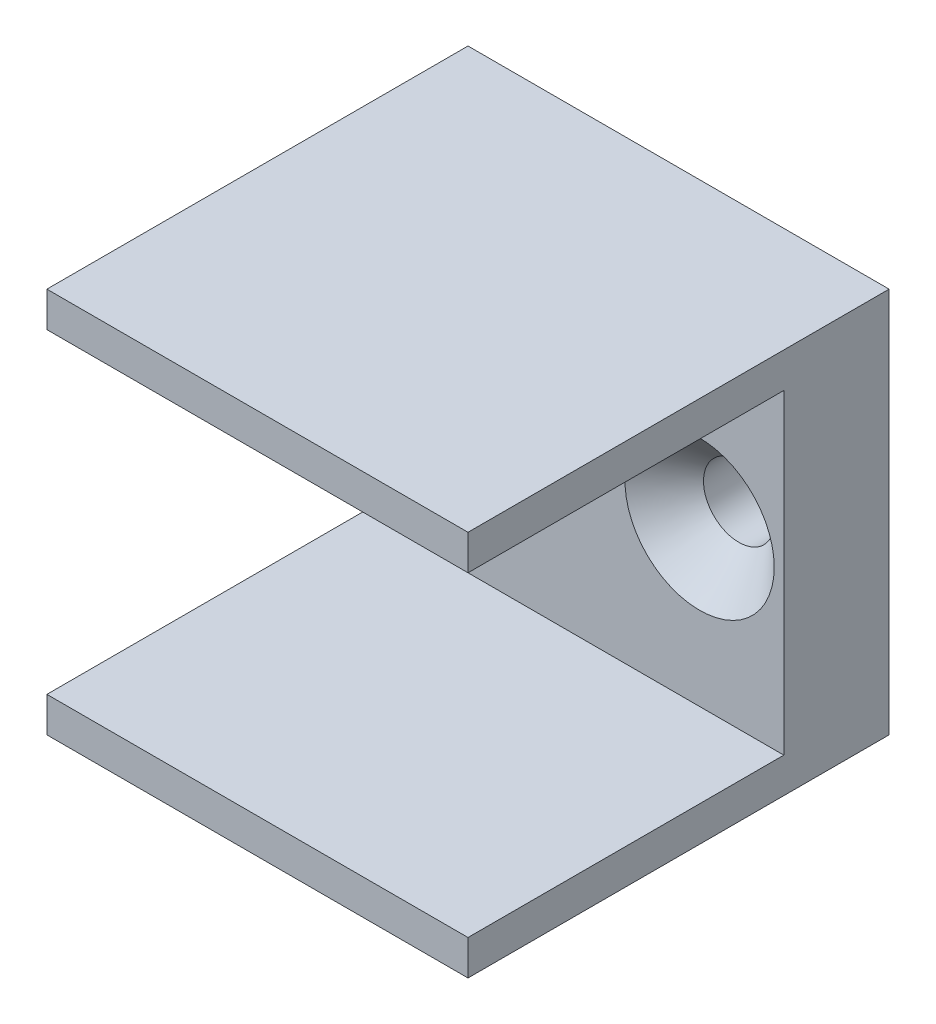
from build123d import *

# Parameters (mm, degrees)
SKETCH1_W                                            = 38.1
SKETCH1_H                                            = 34.925
BOSS_EXTRUDE1_DEPTH                                  = 19.05
SKETCH3_W                                            = 38.1
SKETCH3_H                                            = 28.575
CUT_EXTRUDE1_DEPTH                                   = 28.575
CSK_FOR_M6_HEX_SOCKET_COUNTERSUNK_HEAD_S_D           = 6.4
CSK_FOR_M6_HEX_SOCKET_COUNTERSUNK_HEAD_S_CSINK_D     = 13.5
CSK_FOR_M6_HEX_SOCKET_COUNTERSUNK_HEAD_S_CSINK_ANGLE = 90


with BuildPart() as part:
    # Sketch1 → Boss-Extrude1 (new body, symmetric)
    with BuildSketch(Plane.XY):
        Rectangle(SKETCH1_W, SKETCH1_H)
    extrude(amount=BOSS_EXTRUDE1_DEPTH, both=True)

    # Sketch3 → Cut-Extrude1 (cut)
    with BuildSketch(Plane.XY.offset(19.05)):
        Rectangle(SKETCH3_W, SKETCH3_H)
    extrude(amount=-CUT_EXTRUDE1_DEPTH, mode=Mode.SUBTRACT)

    # CSK for M6 Hex Socket Countersunk Head Screw1 (through all)
    with Locations(Plane.XY.offset(-9.525)):
        with Locations((-11.43, 0), (11.43, 0)):
            CounterSinkHole(CSK_FOR_M6_HEX_SOCKET_COUNTERSUNK_HEAD_S_D / 2, CSK_FOR_M6_HEX_SOCKET_COUNTERSUNK_HEAD_S_CSINK_D / 2, counter_sink_angle=CSK_FOR_M6_HEX_SOCKET_COUNTERSUNK_HEAD_S_CSINK_ANGLE)


solid = part.part
